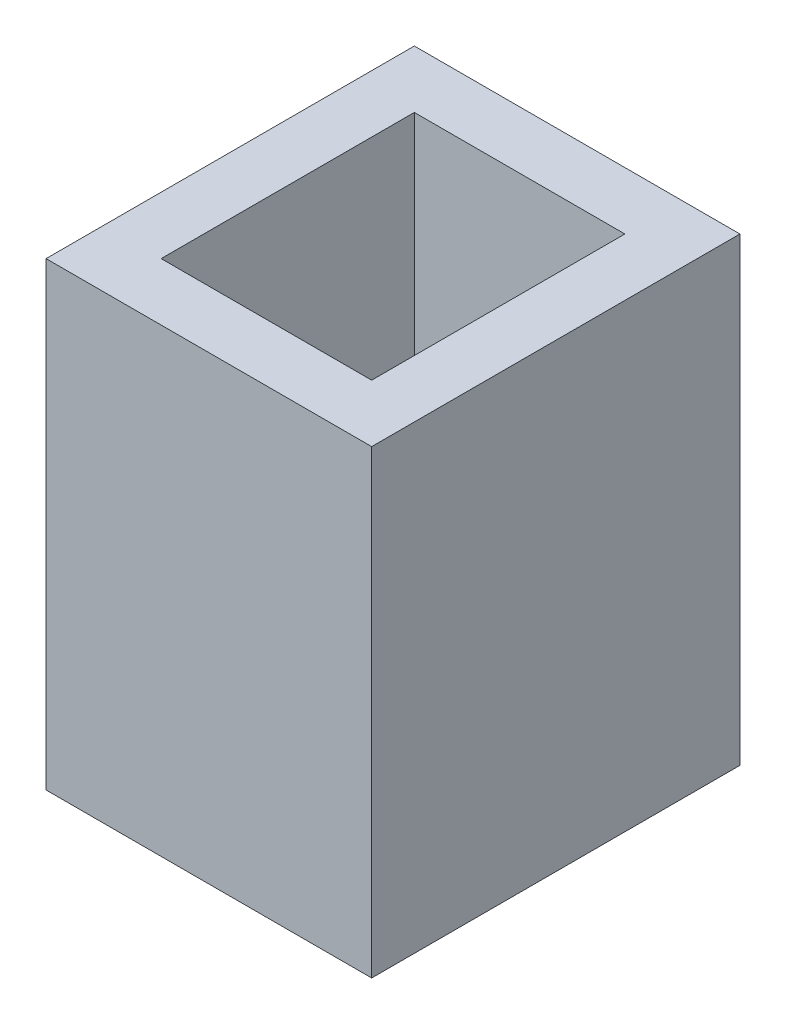
from build123d import *

# Parameters (mm, degrees)
SKETCH1_W           = 17.9705
SKETCH1_H           = 20.32508
SKETCH1_W_2         = 11.6205
SKETCH1_H_2         = 13.97508
BOSS_EXTRUDE1_DEPTH = 25.4


with BuildPart() as part:
    # Sketch1 → Boss-Extrude1 (new body)
    with BuildSketch(Plane(origin=(0, 0, 0), x_dir=(1, 0, 0), z_dir=(0, 1, 0))):
        Rectangle(SKETCH1_W, SKETCH1_H)
        Rectangle(SKETCH1_W_2, SKETCH1_H_2, mode=Mode.SUBTRACT)
    extrude(amount=BOSS_EXTRUDE1_DEPTH)


solid = part.part
